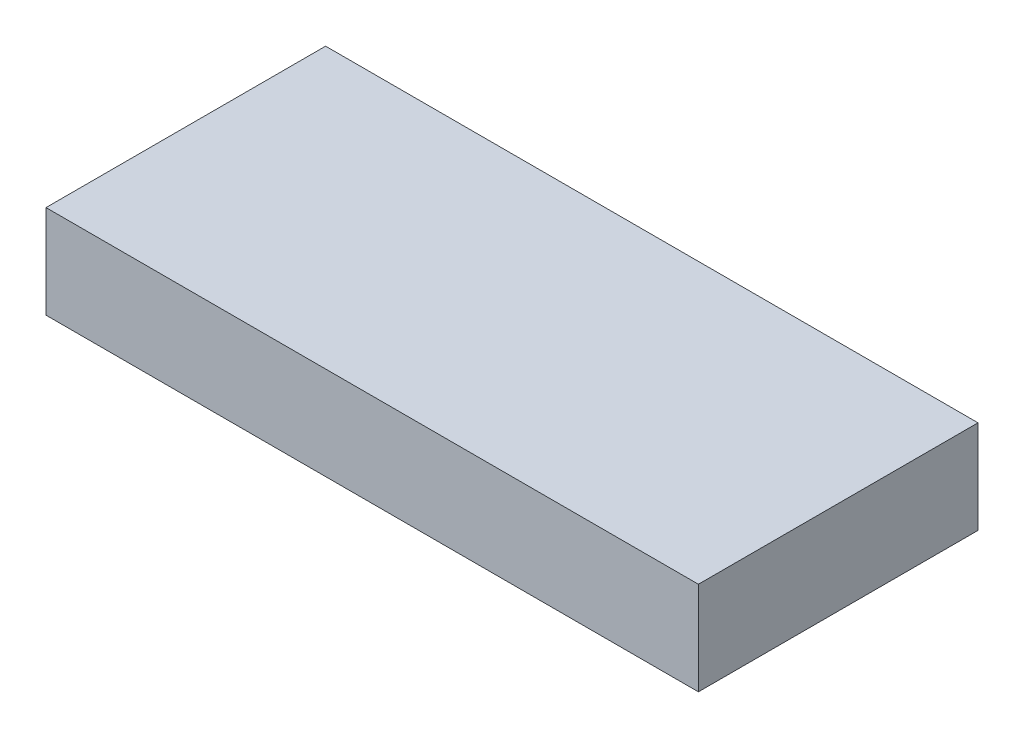
from build123d import *

# Parameters (mm, degrees)
SKETCH1_W      = 17.78
SKETCH1_H      = 7.62
EXTRUDE1_DEPTH = 2.54


with BuildPart() as part:
    # Sketch1 → Extrude1 (new body)
    with BuildSketch(Plane(origin=(0, 0, 0), x_dir=(1, 0, 0), z_dir=(0, 1, 0))):
        Rectangle(SKETCH1_W, SKETCH1_H)
    extrude(amount=EXTRUDE1_DEPTH)


solid = part.part
